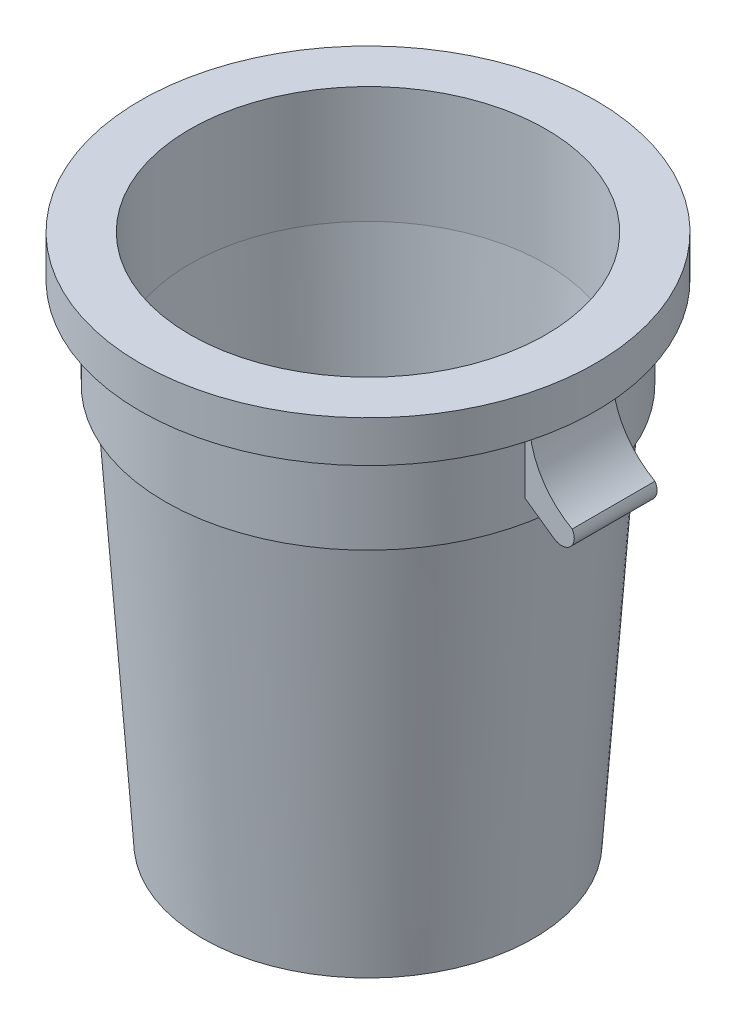
from build123d import *

# Parameters (mm, degrees)
BOSS_EXTRUDE1_DEPTH      = 50.8
BOSS_EXTRUDE1_DEPTH_BACK = 50.8


with BuildPart() as part:
    # Sketch1 → Revolve1 (revolve)
    with BuildSketch(Plane.XY):
        Polygon((0, 19.05), (0, 0), (203.2, 0), (236.22, 486.918), (248.92, 486.918), (248.92, 598.424), (254, 598.424), (254, 617.474), (266.7, 617.474), (266.7, 598.424), (279.4, 598.424), (279.4, 649.224), (218.418109166, 649.224), (218.418109166, 505.968), (185.398109166, 19.05), align=None)
    revolve(axis=Axis((0, 19.05, 0), (0, -1, 0)))

    # Sketch2 → Boss-Extrude1 (add, two sides: drawn at the far end of the back side and taken through both)
    with BuildSketch(Plane.XY.offset(-BOSS_EXTRUDE1_DEPTH_BACK)):
        with BuildLine():
            Line((248.92, 509.524), (279.4, 488.181674235))
            ThreePointArc((279.4, 488.181674235), (299.197311316, 489.777633759), (301.333111503, 509.524))
            ThreePointArc((301.333111503, 509.524), (262.998722955, 546.823747439), (248.92, 598.424))
            Line((248.92, 598.424), (236.22, 598.424))
            Line((236.22, 598.424), (236.22, 518.416635735))
            Line((236.22, 518.416635735), (248.92, 509.524))
        make_face()
    extrude(amount=BOSS_EXTRUDE1_DEPTH + BOSS_EXTRUDE1_DEPTH_BACK)


solid = part.part
